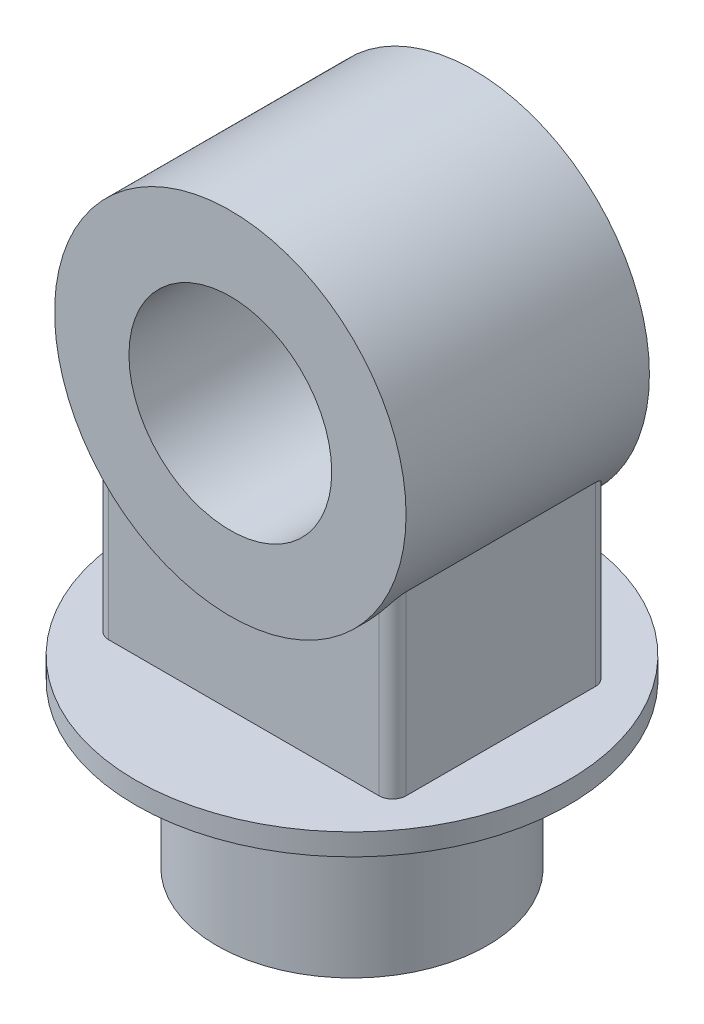
from build123d import *

# Parameters (mm, degrees)
SKETCH_1_R           = 100
EXTRUDE_1_DEPTH      = 120
SKETCH_2_R           = 160
EXTRUDE_2_DEPTH      = 16
SKETCH_3_R           = 130
SKETCH_3_R_2         = 75
EXTRUDE_3_DEPTH      = 90
EXTRUDE_4_REACH      = 402.125
EXTRUDE_4_END_RADIUS = 130
SKETCH_4_W           = 220
SKETCH_4_H           = 160
FILLET_1_R           = 10


with BuildPart() as part:
    # 草图1 → 凸台-拉伸1 (new body)
    with BuildSketch(Plane(origin=(0, 0, 0), x_dir=(1, 0, 0), z_dir=(0, 1, 0))):
        with Locations(Location((0, 0, 0), (0, 0, 270))):
            Circle(SKETCH_1_R)
    extrude(amount=EXTRUDE_1_DEPTH)

    # 草图2 → 凸台-拉伸2 (add)
    with BuildSketch(Plane(origin=(0, 120, 0), x_dir=(1, 0, 0), z_dir=(0, 1, 0))):
        with Locations(Location((0, 0, 0), (0, 0, 270))):
            Circle(SKETCH_2_R)
    extrude(amount=EXTRUDE_2_DEPTH)



with BuildPart() as body_2:
    # 草图3 → 凸台-拉伸3 (new, symmetric)
    with BuildSketch(Plane.XY):
        with Locations(Location((0, 336, 0), (0, 0, 180))):
            Circle(SKETCH_3_R)
        with Locations(Location((0, 336, 0), (0, 0, 180))):
            Circle(SKETCH_3_R_2, mode=Mode.SUBTRACT)
    extrude(amount=EXTRUDE_3_DEPTH, both=True)


with BuildPart() as part_1:
    add(part.part)

    add(body_2.part)  # 凸台-拉伸4 merges body 2
    # 凸台-拉伸4: up to this cylinder (the profile starts outside it)
    extrude_4_end = Plane(origin=(0, 336, 0), z_dir=(0, 0, -1)) * Cylinder(EXTRUDE_4_END_RADIUS, 1065.25, mode=Mode.PRIVATE)
    # 草图4 → 凸台-拉伸4 (add, up to the surface)
    with BuildSketch(Plane(origin=(0, 136, 0), x_dir=(1, 0, 0), z_dir=(0, 1, 0)), mode=Mode.PRIVATE) as extrude_4_sk1:
        Rectangle(SKETCH_4_W, SKETCH_4_H)
    extrude_4_tool1 = extrude(extrude_4_sk1.sketch, amount=EXTRUDE_4_REACH, mode=Mode.PRIVATE) - extrude_4_end
    add(extrude_4_tool1.solids().sort_by_distance((0, 136, 0))[0])

    # 圆角1
    fillet_1_edges = [part_1.edges().sort_by_distance(p)[0] for p in [
        (110, 201.358983849, -80),
        (110, 201.358983849, 80),
        (-110, 201.358983849, -80),
        (-110, 201.358983849, 80),
    ]]
    fillet(fillet_1_edges, radius=FILLET_1_R)


solid = part_1.part
